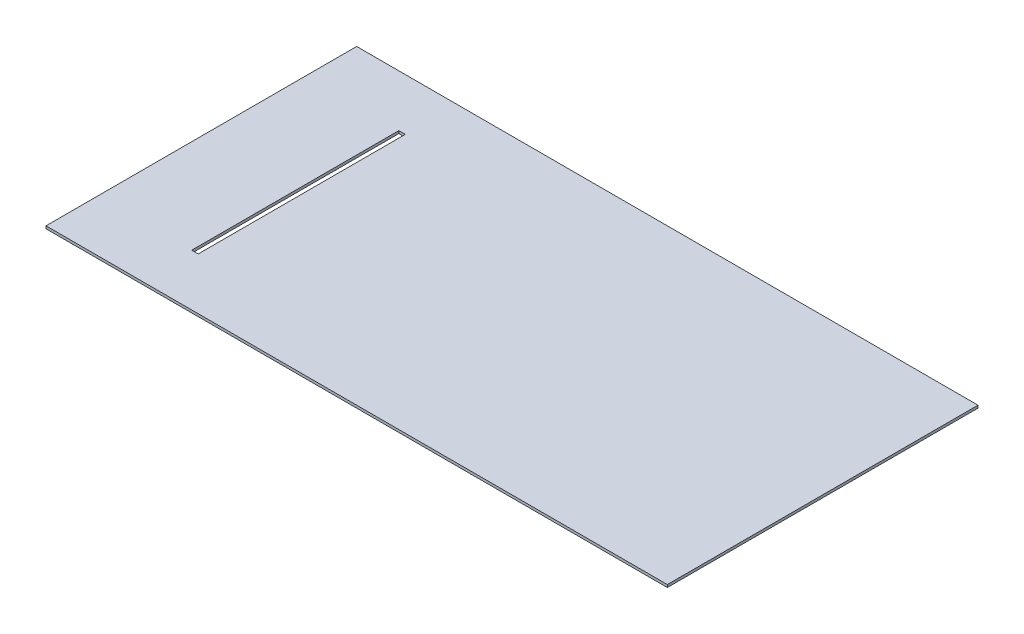
from build123d import *

# Parameters (mm, degrees)
SKETCH1_W           = 609.6
SKETCH1_H           = 304.8
BOSS_EXTRUDE1_DEPTH = 2.54
SKETCH2_W           = 6.35
SKETCH2_H           = 203.2
CUT_EXTRUDE1_DEPTH  = 54.864


with BuildPart() as part:
    # Sketch1 → Boss-Extrude1 (new body)
    with BuildSketch(Plane(origin=(0, 0, 0), x_dir=(1, 0, 0), z_dir=(0, 1, 0))):
        with Locations((304.8, 152.4)):
            Rectangle(SKETCH1_W, SKETCH1_H)
    extrude(amount=BOSS_EXTRUDE1_DEPTH)

    # Sketch2 → Cut-Extrude1 (cut)
    with BuildSketch(Plane(origin=(0, 2.54, 0), x_dir=(1, 0, 0), z_dir=(0, 1, 0))):
        with Locations((95.378510318, 152.4)):
            Rectangle(SKETCH2_W, SKETCH2_H)
    extrude(amount=-CUT_EXTRUDE1_DEPTH, mode=Mode.SUBTRACT)


solid = part.part
